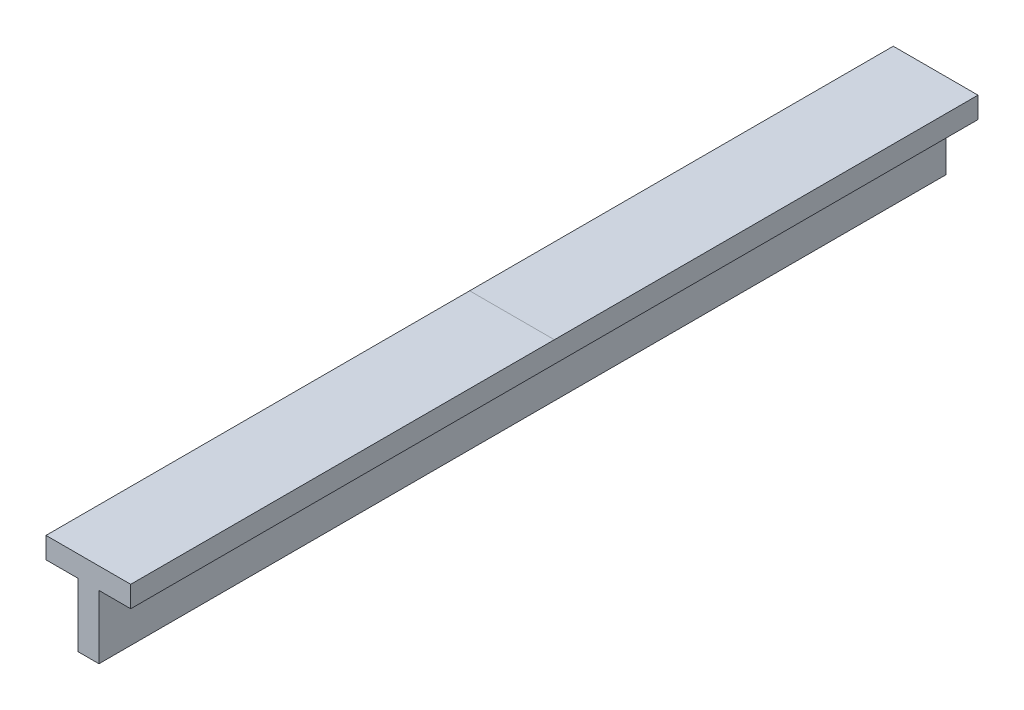
from build123d import *

# Parameters (mm, degrees)
DODANIE_WYCI_GNI_CIE1_DEPTH = 2000


with BuildPart() as part:
    # Szkic1 → Dodanie-wyciągnięcie1 (new body)
    with BuildSketch(Plane.XY):
        Polygon((0, 0), (50, 0), (50, 150), (125, 150), (125, 200), (-75, 200), (-75, 150), (0, 150), align=None)
    extrude(amount=DODANIE_WYCI_GNI_CIE1_DEPTH)


solid = part.part
